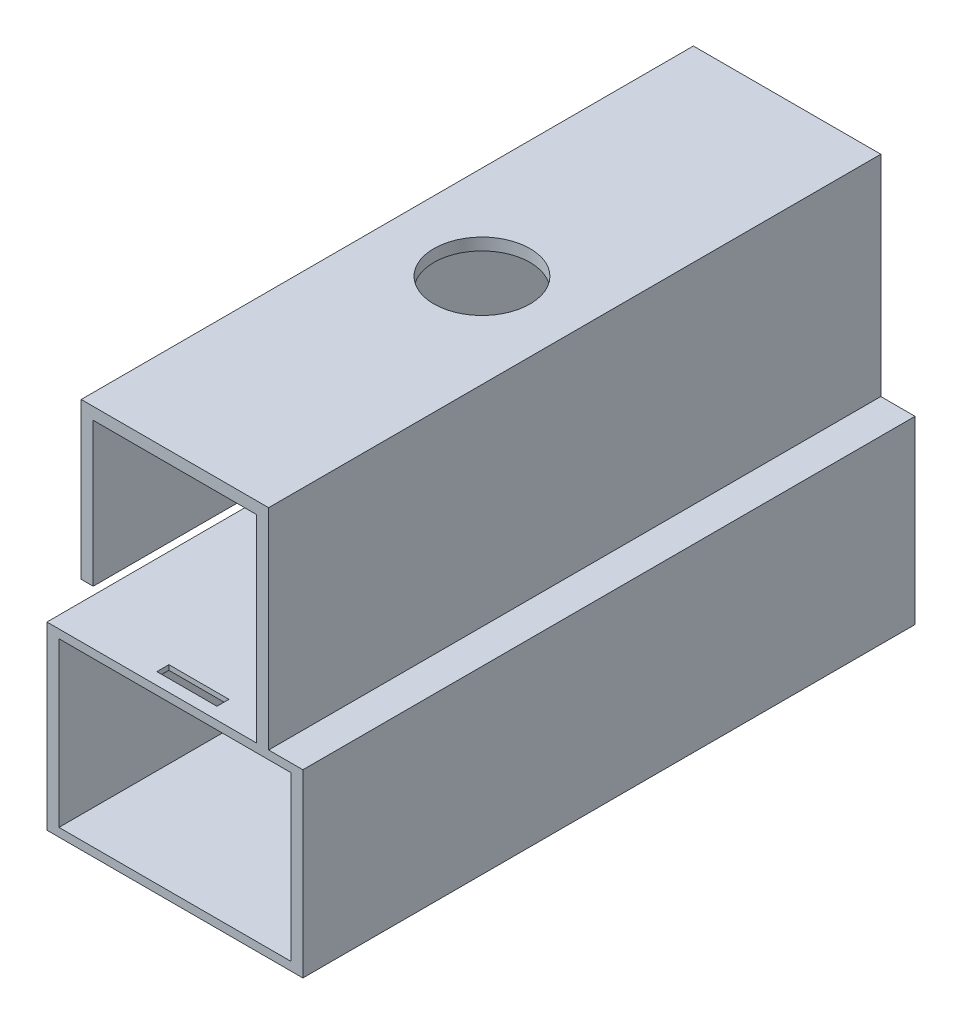
from build123d import *

# Parameters (mm, degrees)
SKETCH1_W                = 42.6
SKETCH1_H                = 30.01865285
SKETCH1_W_2              = 38.6
SKETCH1_H_2              = 27.2
BOSS_EXTRUDE1_DEPTH      = 101.9
BOSS_EXTRUDE2_DEPTH      = 13.6
BOSS_EXTRUDE2_DEPTH_BACK = 13.6
SKETCH4_W                = 2
SKETCH4_H                = 34.93
BOSS_EXTRUDE3_DEPTH      = 101.9
SKETCH5_R                = 8
CUT_EXTRUDE1_DEPTH       = 2
CUT_EXTRUDE2_REACH       = 38.339
SKETCH6_W                = 10
SKETCH6_H                = 2
SKETCH7_W                = 12
SKETCH7_H                = 4
SKETCH7_W_2              = 10
SKETCH7_H_2              = 2
CUT_EXTRUDE3_DEPTH       = 0.6
SKETCH8_W                = 2
SKETCH8_H                = 9
CUT_EXTRUDE4_DEPTH       = 70


with BuildPart() as part:
    # Sketch1 → Boss-Extrude1 (new body)
    with BuildSketch(Plane.XY):
        Rectangle(SKETCH1_W, SKETCH1_H)
        Rectangle(SKETCH1_W_2, SKETCH1_H_2, mode=Mode.SUBTRACT)
    extrude(amount=BOSS_EXTRUDE1_DEPTH)

    # Sketch3 → Boss-Extrude2 (add, two sides)
    with BuildSketch(Plane(origin=(0, 0, 0), x_dir=(0, 0, -1), z_dir=(1, 0, 0))) as boss_extrude2_sk:
        with BuildLine():
            Line((-12, 15.009326425), (0, 15.009326425))
            Line((0, 15.009326425), (0, 49.939326425))
            Line((0, 49.939326425), (-101.9, 49.939326425))
            Line((-101.9, 49.939326425), (-101.9, 47.939326425))
            Line((-101.9, 47.939326425), (-12, 47.939326425))
            Line((-12, 47.939326425), (-12, 45.640749382))
            ThreePointArc((-12, 45.640749382), (-11.256013823, 43.317309263), (-9.300813008, 41.85817281))
            ThreePointArc((-9.300813008, 41.85817281), (-3.719128817, 33.446145776), (-10.388349515, 25.867300712))
            ThreePointArc((-10.388349515, 25.867300712), (-11.545428586, 25.174874775), (-12, 23.905366805))
            Line((-12, 23.905366805), (-12, 15.009326425))
        make_face()
    extrude(amount=BOSS_EXTRUDE2_DEPTH)
    extrude(boss_extrude2_sk.sketch, amount=-BOSS_EXTRUDE2_DEPTH_BACK)

    # Sketch4 → Boss-Extrude3 (add)
    with BuildSketch(Plane(origin=(0, 0, 0), x_dir=(-1, 0, 0), z_dir=(0, 0, -1))):
        with Locations((14.6, 32.474326425)):
            Rectangle(SKETCH4_W, SKETCH4_H)
        with Locations((-14.6, 32.474326425)):
            Rectangle(SKETCH4_W, SKETCH4_H)
    extrude(amount=-BOSS_EXTRUDE3_DEPTH)

    # Sketch5 → Cut-Extrude1 (cut)
    with BuildSketch(Plane(origin=(0, 49.939326425, 0), x_dir=(1, 0, 0), z_dir=(0, 1, 0))):
        with Locations((0, -50.788349515)):
            Circle(SKETCH5_R)
    extrude(amount=-CUT_EXTRUDE1_DEPTH, mode=Mode.SUBTRACT)

    # Sketch6 → Cut-Extrude2 (cut, up to next)
    with BuildSketch(Plane.XZ.offset(-13.6), mode=Mode.PRIVATE) as cut_extrude2_sk1:
        with Locations((0, 98.9)):
            Rectangle(SKETCH6_W, SKETCH6_H)
    cut_extrude2_tool1 = extrude(cut_extrude2_sk1.sketch, amount=-CUT_EXTRUDE2_REACH, mode=Mode.PRIVATE) & part.part
    add(cut_extrude2_tool1.solids().sort_by_distance((0, 13.6, 98.9))[0], mode=Mode.SUBTRACT)

    # Sketch7 → Cut-Extrude3 (cut)
    with BuildSketch(Plane.XZ.offset(-13.6)):
        with Locations((0, 98.9)):
            Rectangle(SKETCH7_W, SKETCH7_H)
        with Locations((0, 98.9)):
            Rectangle(SKETCH7_W_2, SKETCH7_H_2, mode=Mode.SUBTRACT)
    extrude(amount=-CUT_EXTRUDE3_DEPTH, mode=Mode.SUBTRACT)

    # Sketch8 → Cut-Extrude4 (cut)
    with BuildSketch(Plane.XY.offset(101.9)):
        with Locations((-14.6, 19.509326425)):
            Rectangle(SKETCH8_W, SKETCH8_H)
    extrude(amount=-CUT_EXTRUDE4_DEPTH, mode=Mode.SUBTRACT)


solid = part.part
